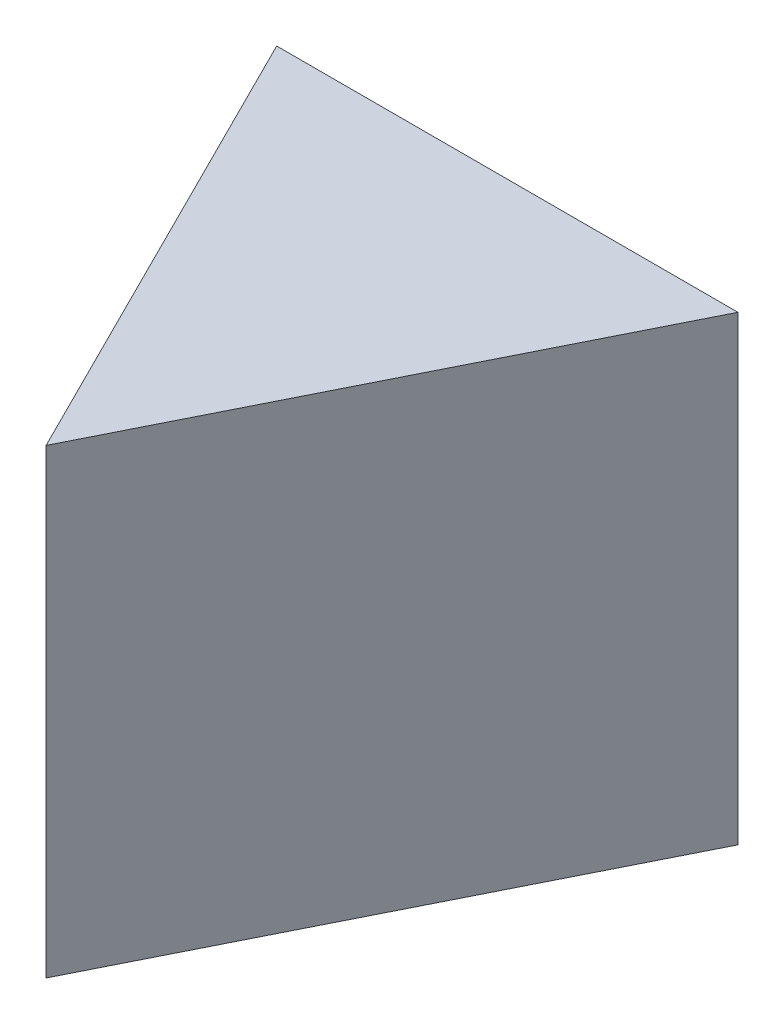
from build123d import *

# Parameters (mm, degrees)
SKETCH1_W           = 20
SKETCH1_H           = 20
BOSS_EXTRUDE1_DEPTH = 20
CUT_EXTRUDE1_DEPTH  = 20
CUT_EXTRUDE2_DEPTH  = 20


with BuildPart() as part:
    # Sketch1 → Boss-Extrude1 (new body)
    with BuildSketch(Plane.XY):
        with Locations((10, 10)):
            Rectangle(SKETCH1_W, SKETCH1_H)
    extrude(amount=BOSS_EXTRUDE1_DEPTH)

    # Sketch2 → Cut-Extrude1 (cut)
    with BuildSketch(Plane(origin=(0, 20, 0), x_dir=(1, 0, 0), z_dir=(0, 1, 0))):
        Polygon((0, 0), (10, -20), (0, -20), align=None)
    extrude(amount=-CUT_EXTRUDE1_DEPTH, mode=Mode.SUBTRACT)

    # Sketch3 → Cut-Extrude2 (cut)
    with BuildSketch(Plane(origin=(0, 20, 0), x_dir=(1, 0, 0), z_dir=(0, 1, 0))):
        Polygon((20, 0), (10, -20), (20, -20), align=None)
    extrude(amount=-CUT_EXTRUDE2_DEPTH, mode=Mode.SUBTRACT)


solid = part.part
